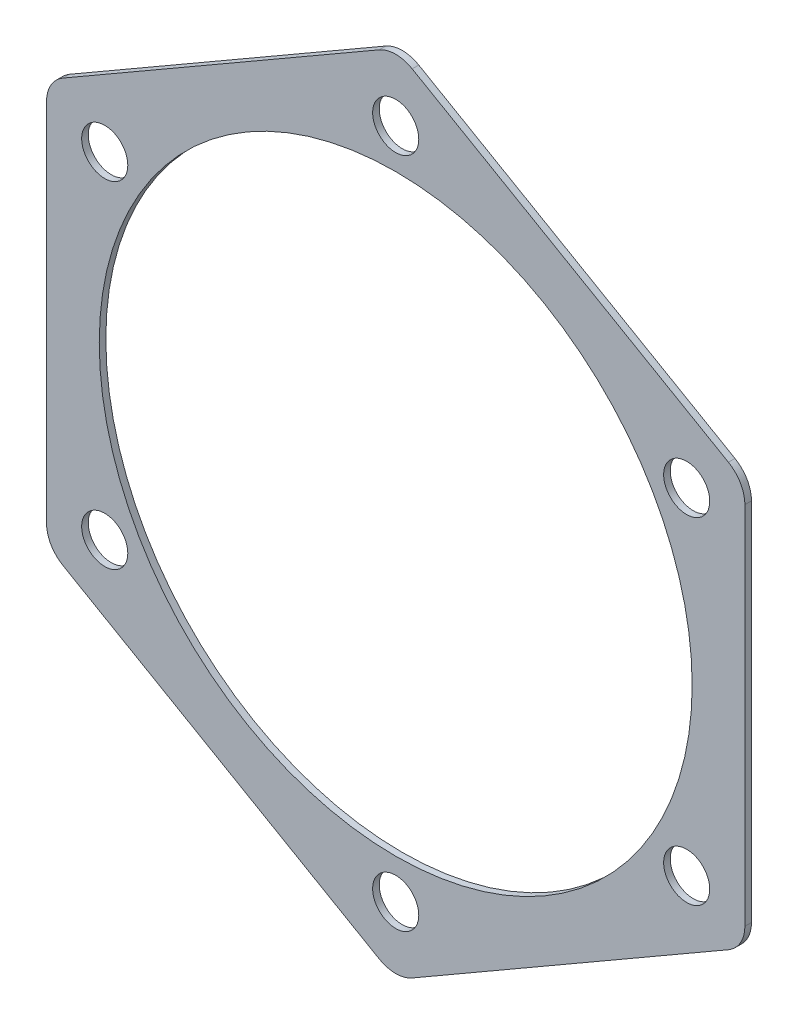
from build123d import *

# Parameters (mm, degrees)
SKETCH1_R           = 45
SKETCH1_R_2         = 3.5
BOSS_EXTRUDE1_DEPTH = 1


with BuildPart() as part:
    # Sketch1 → Boss-Extrude1 (new body)
    with BuildSketch(Plane.XY):
        with BuildLine():
            Line((-50.5, -32.04293994), (-2.5, -59.755752861))
            ThreePointArc((-2.5, -59.755752861), (0, -60.425625842), (2.5, -59.755752861))
            Line((2.5, -59.755752861), (50.5, -32.04293994))
            ThreePointArc((50.5, -32.04293994), (52.330127019, -30.212812921), (53, -27.712812921))
            Line((53, -27.712812921), (53, 27.712812921))
            ThreePointArc((53, 27.712812921), (52.330127019, 30.212812921), (50.5, 32.04293994))
            Line((50.5, 32.04293994), (2.5, 59.755752861))
            ThreePointArc((2.5, 59.755752861), (0, 60.425625842), (-2.5, 59.755752861))
            Line((-2.5, 59.755752861), (-50.5, 32.04293994))
            ThreePointArc((-50.5, 32.04293994), (-52.330127019, 30.212812921), (-53, 27.712812921))
            Line((-53, 27.712812921), (-53, -27.712812921))
            ThreePointArc((-53, -27.712812921), (-52.330127019, -30.212812921), (-50.5, -32.04293994))
        make_face()
        Circle(SKETCH1_R, mode=Mode.SUBTRACT)
        with Locations((0, 51)):
            Circle(SKETCH1_R_2, mode=Mode.SUBTRACT)
        with Locations((44.167295593, 25.5)):
            Circle(SKETCH1_R_2, mode=Mode.SUBTRACT)
        with Locations((44.167295593, -25.5)):
            Circle(SKETCH1_R_2, mode=Mode.SUBTRACT)
        with Locations((0, -51)):
            Circle(SKETCH1_R_2, mode=Mode.SUBTRACT)
        with Locations((-44.167295593, -25.5)):
            Circle(SKETCH1_R_2, mode=Mode.SUBTRACT)
        with Locations((-44.167295593, 25.5)):
            Circle(SKETCH1_R_2, mode=Mode.SUBTRACT)
    extrude(amount=BOSS_EXTRUDE1_DEPTH)


solid = part.part
